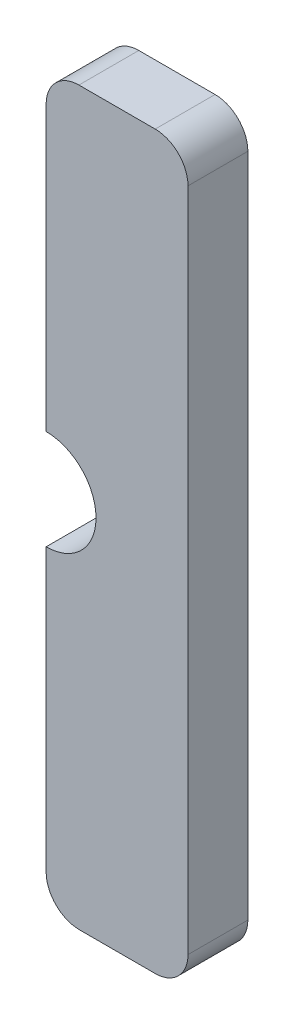
from build123d import *

# Parameters (mm, degrees)
EXTRUDE_1_DEPTH = 2.1


with BuildPart() as part:
    # Эскиз1 → Бобышка-Вытянуть1 (new body)
    with BuildSketch(Plane(origin=(0, 0, 0), x_dir=(-1, 0, 0), z_dir=(0, 0, -1))):
        with BuildLine():
            Line((-32.400001526, 25.399999619), (-29.75, 25.399999619))
            ThreePointArc((-29.75, 25.399999619), (-28.915971608, 25.747039587), (-28.575035851, 26.583581821))
            Line((-28.575035851, 26.583581821), (-28.575035851, 36.450190384))
            ThreePointArc((-28.575035851, 36.450190384), (-30.325030381, 38.200184914), (-28.575035851, 39.950179444))
            Line((-28.575035851, 39.950179444), (-28.575035851, 49.908417469))
            ThreePointArc((-28.575035851, 49.908417469), (-28.914981331, 50.715971039), (-29.725000381, 51.049999237))
            Line((-29.725000381, 51.049999237), (-32.400001526, 51.049999237))
            ThreePointArc((-32.400001526, 51.049999237), (-33.213001251, 50.713001251), (-33.549999237, 49.900001526))
            Line((-33.549999237, 49.900001526), (-33.549999237, 26.549999237))
            ThreePointArc((-33.549999237, 26.549999237), (-33.213000972, 25.736999232), (-32.400001526, 25.399999619))
        make_face()
    extrude(amount=-EXTRUDE_1_DEPTH)


solid = part.part
